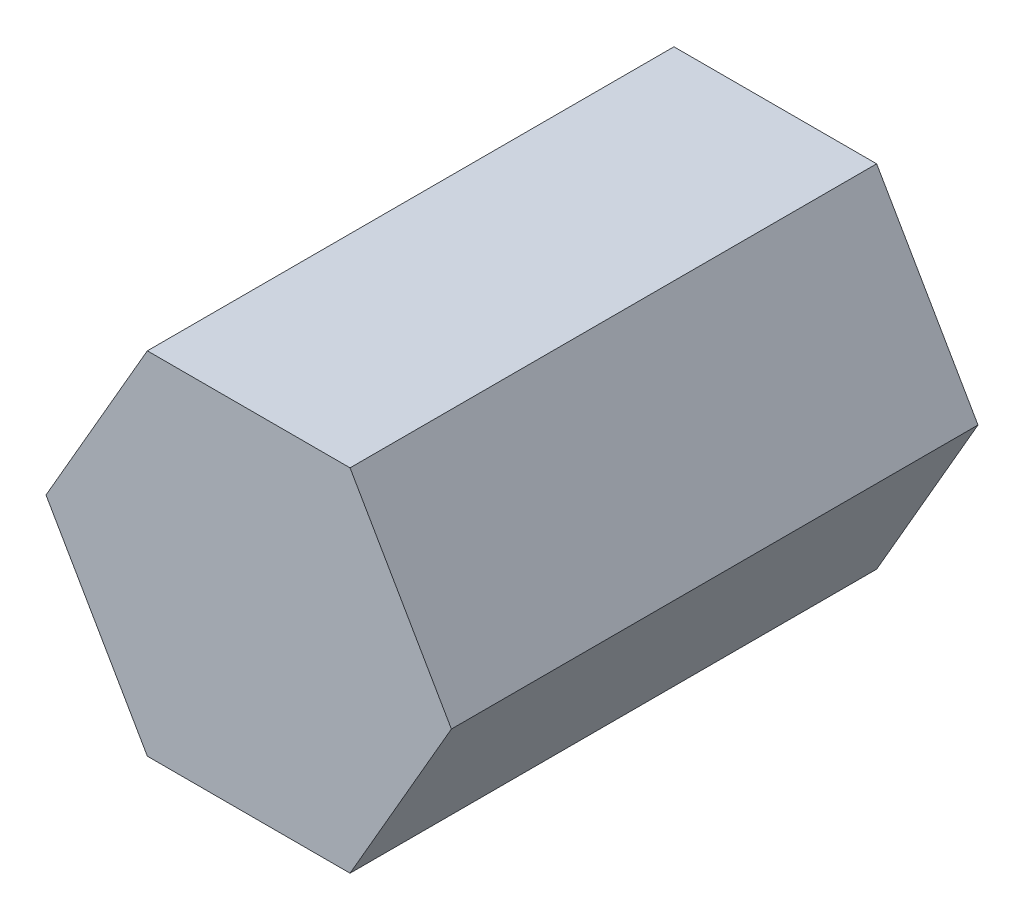
from build123d import *

# Parameters (mm, degrees)
BOSS_EXTRUDE1_DEPTH = 37.5


with BuildPart() as part:
    # Sketch1 → Boss-Extrude1 (new body, symmetric)
    with BuildSketch(Plane.XY):
        Polygon((14.43375673, 25), (-14.43375673, 25), (-28.867513459, 0), (-14.43375673, -25), (14.43375673, -25), (28.867513459, 0), align=None)
    extrude(amount=BOSS_EXTRUDE1_DEPTH, both=True)


solid = part.part
